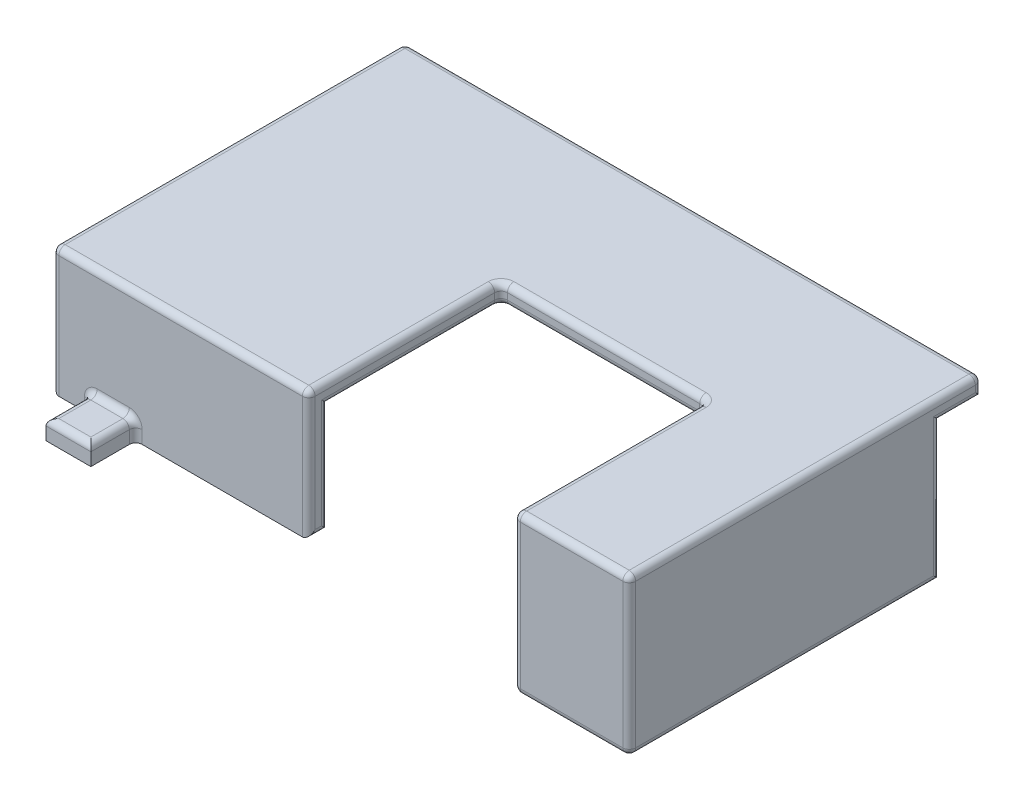
from build123d import *

# Parameters (mm, degrees)
SKETCH1_W           = 90
SKETCH1_H           = 55
BOSS_EXTRUDE1_DEPTH = 3
BOSS_EXTRUDE2_DEPTH = 21.5
SKETCH3_W           = 48.5
SKETCH3_H           = 9
CUT_EXTRUDE1_DEPTH  = 3
CUT_EXTRUDE2_DEPTH  = 30
SKETCH7_W           = 3
SKETCH7_H           = 4.504117268
BOSS_EXTRUDE3_DEPTH = 3
SKETCH8_W           = 7
SKETCH8_H           = 3
BOSS_EXTRUDE4_DEPTH = 7
FILLET1_R           = 1


with BuildPart() as part:
    # Sketch1 → Boss-Extrude1 (new body)
    with BuildSketch(Plane(origin=(0, 0, 0), x_dir=(1, 0, 0), z_dir=(0, 1, 0))):
        with Locations((45, 27.5)):
            Rectangle(SKETCH1_W, SKETCH1_H)
    extrude(amount=BOSS_EXTRUDE1_DEPTH)

    # Sketch2 → Boss-Extrude2 (add)
    with BuildSketch(Plane.XZ):
        Polygon((3, 0), (0, 0), (0, -48.5), (3, -48.5), (3, -3), (87, -3), (87, -48.5), (90, -48.5), (90, -3), (90, 0), align=None)
    extrude(amount=BOSS_EXTRUDE2_DEPTH)

    # Sketch3 → Cut-Extrude1 (cut)
    with BuildSketch(Plane.ZY):
        with Locations((-24.25, -17)):
            Rectangle(SKETCH3_W, SKETCH3_H)
    extrude(amount=-CUT_EXTRUDE1_DEPTH, mode=Mode.SUBTRACT)

    # Sketch4 → Cut-Extrude2 (cut)
    with BuildSketch(Plane.XY):
        Polygon((3, -17.004117268), (3, -21.5), (57, -21.5), (72, -21.5), (72, 3), (40, 3), (40, -17.004117268), align=None)
    extrude(amount=-CUT_EXTRUDE2_DEPTH, mode=Mode.SUBTRACT)

    # Sketch7 → Boss-Extrude3 (add)
    with BuildSketch(Plane.ZY.offset(-3)):
        with Locations((-1.5, -14.752058634)):
            Rectangle(SKETCH7_W, SKETCH7_H)
    extrude(amount=BOSS_EXTRUDE3_DEPTH)

    # Sketch8 → Boss-Extrude4 (add)
    with BuildSketch(Plane.XY):
        with Locations((9.5, -15.504117268)):
            Rectangle(SKETCH8_W, SKETCH8_H)
    extrude(amount=BOSS_EXTRUDE4_DEPTH)

    # Fillet1
    fillet1_edges = [part.edges().sort_by_distance(p)[0] for p in [
        (6, -15.504117268, 0),
        (6, -14.004117268, 3.5),
        (13, -15.504117268, 0),
        (9.5, -14.004117268, 0),
        (13, -14.004117268, 3.5),
        (9.5, -14.004117268, 7),
        (90, 3, -27.5),
        (90, 0, -51.75),
        (45, 3, -55),
        (90, -10.75, -48.5),
        (90, -21.5, -24.25),
        (81, -21.5, 0),
        (0, -6.25, -48.5),
        (0, 3, -27.5),
        (0, 0, -51.75),
        (40, -8.502058634, -3),
        (56, 0, -30),
        (81, 3, 0),
        (72, 0, -16.5),
        (72, -21.5, -1.5),
        (40, 0, -16.5),
        (40, -17.004117268, -1.5),
        (40, -7.002058634, 0),
        (56, 3, -30),
        (40, 3, -15),
        (72, 1.5, -30),
        (72, 3, -15),
        (72, -10.75, -3),
        (40, 1.5, -30),
        (72, -9.25, 0),
        (0, 1.5, -55),
        (90, 1.5, -55),
        (90, -9.25, 0),
        (0, -7.002058634, 0),
        (20, 3, 0),
        (0, -12.5, -25.75),
        (0, -14.752058634, -3),
        (0, -17.004117268, -1.5),
    ]]
    fillet(fillet1_edges, radius=FILLET1_R)


solid = part.part
